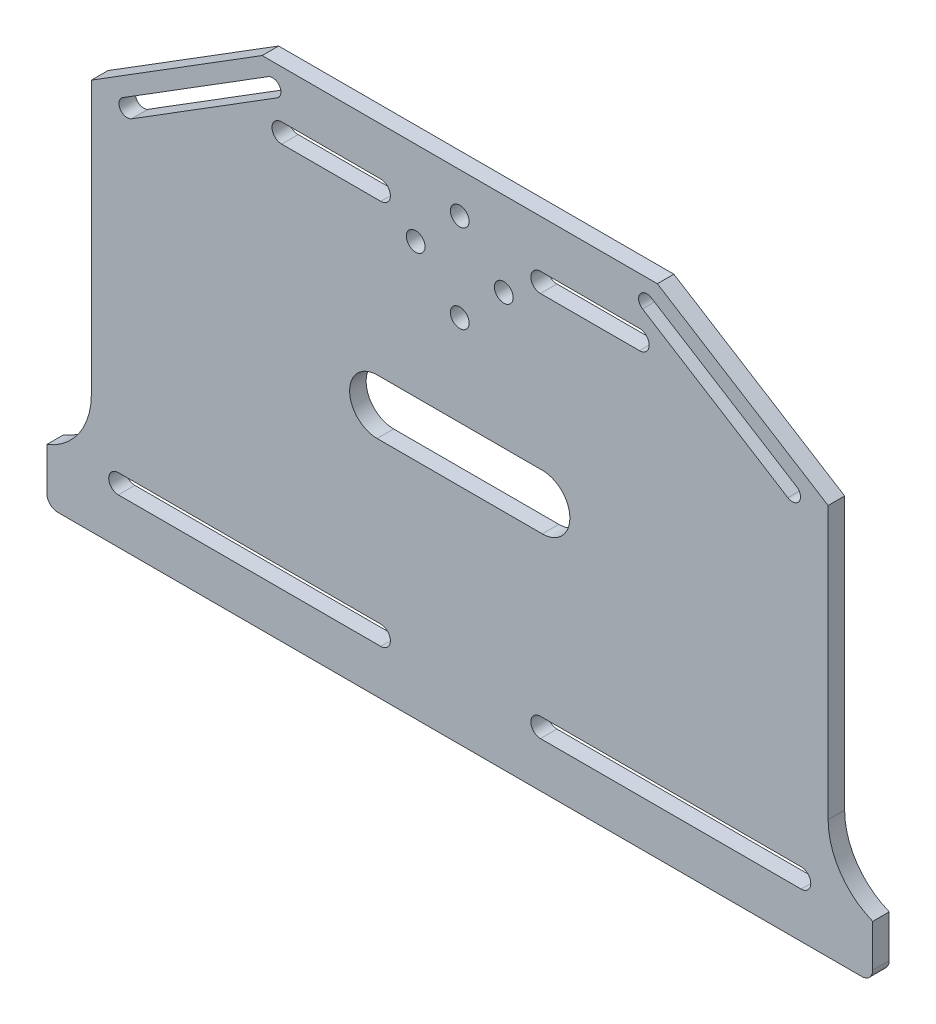
from build123d import *

# Parameters (mm, degrees)
EXTRUDE_1_DEPTH      = 3
SKETCH_7_R           = 1.75
SKETCH_7_R_2         = 2.25
CUT_EXTRUDE_2_DEPTH  = 143.955430949
CUT_EXTRUDE_4_DEPTH  = 3
CUT_EXTRUDE_5_DEPTH  = 3
CUT_EXTRUDE_8_DEPTH  = 3
SKETCH_12_R          = 1.7
CUT_EXTRUDE_9_DEPTH  = 3
SKETCH_13_R          = 1.7
CUT_EXTRUDE_11_DEPTH = 3
CUT_EXTRUDE_12_DEPTH = 143.955430949
FILLET_1_R           = 2
FILLET_2_R           = 2
CUT_EXTRUDE_13_DEPTH = 143.955430949
CUT_EXTRUDE_15_DEPTH = 143.955430949
CUT_EXTRUDE_16_DEPTH = 143.955430949
SKETCH_20_W          = 133.80338819
SKETCH_20_H          = 42.989432067
EXTRUDE_2_DEPTH      = 3
SKETCH_21_W          = 129.207272524
SKETCH_21_H          = 38.788932745
EXTRUDE_3_DEPTH      = 3
SKETCH_22_W          = 20.868569364
SKETCH_22_H          = 31.210515244
SKETCH_22_W_2        = 21.053246969
SKETCH_22_H_2        = 30.102449614
EXTRUDE_4_DEPTH      = 3
SKETCH_24_W          = 36.300662223
SKETCH_24_H          = 5.953308604
SKETCH_24_W_2        = 36.591067521
EXTRUDE_5_DEPTH      = 3
CUT_EXTRUDE_17_DEPTH = 143.955430949
CUT_EXTRUDE_19_DEPTH = 143.955430949
CUT_EXTRUDE_20_DEPTH = 143.955430949
CUT_EXTRUDE_21_DEPTH = 143.955430949
CUT_EXTRUDE_22_DEPTH = 143.955430949
CUT_EXTRUDE_23_DEPTH = 3
SKETCH_30_W          = 173.170170175
SKETCH_30_H          = 150.145671893
CUT_EXTRUDE_24_DEPTH = 10


with BuildPart() as part:
    # 草图1 → 凸台-拉伸1 (new body)
    with BuildSketch(Plane.XY):
        with BuildLine():
            Line((60, 106.603296002), (35.889163634, 121.664519159))
            Line((35.889163634, 121.664519159), (-35.889163634, 121.664519159))
            Line((-35.889163634, 121.664519159), (-60, 106.603296002))
            Line((-60, 106.603296002), (-60, 94.801892265))
            Line((-60, 94.801892265), (-45, 94.801892265))
            ThreePointArc((-45, 94.801892265), (-43.762563133, 94.289329132), (-43.25, 93.051892265))
            Line((-43.25, 93.051892265), (-37.75, 93.051892265))
            ThreePointArc((-37.75, 93.051892265), (-37.237436867, 94.289329132), (-36, 94.801892265))
            Line((-36, 94.801892265), (-21, 94.801892265))
            ThreePointArc((-21, 94.801892265), (-19.762563133, 94.289329132), (-19.25, 93.051892265))
            Line((-19.25, 93.051892265), (19.25, 93.051892265))
            ThreePointArc((19.25, 93.051892265), (19.762563133, 94.289329132), (21, 94.801892265))
            Line((21, 94.801892265), (36, 94.801892265))
            ThreePointArc((36, 94.801892265), (37.237436867, 94.289329132), (37.75, 93.051892265))
            Line((37.75, 93.051892265), (43.25, 93.051892265))
            ThreePointArc((43.25, 93.051892265), (43.762563133, 94.289329132), (45, 94.801892265))
            Line((45, 94.801892265), (60, 94.801892265))
            Line((60, 94.801892265), (60, 106.603296002))
        make_face()
        with BuildLine():
            Line((66.901694095, 102.292041372), (60, 106.603296002))
            Line((60, 106.603296002), (60, 94.801892265))
            ThreePointArc((60, 94.801892265), (61.237436867, 94.289329132), (61.75, 93.051892265))
            Line((61.75, 93.051892265), (66.901694095, 93.051892265))
            Line((66.901694095, 93.051892265), (66.901694095, 102.292041372))
        make_face()
        with BuildLine():
            Line((-60, 94.801892265), (-60, 106.603296002))
            Line((-60, 106.603296002), (-66.901694095, 102.292041372))
            Line((-66.901694095, 102.292041372), (-66.901694095, 93.051892265))
            Line((-66.901694095, 93.051892265), (-61.75, 93.051892265))
            ThreePointArc((-61.75, 93.051892265), (-61.237436867, 94.289329132), (-60, 94.801892265))
        make_face()
        with BuildLine():
            Line((66.901694095, 63.051892265), (66.901694095, 93.051892265))
            Line((66.901694095, 93.051892265), (61.75, 93.051892265))
            ThreePointArc((61.75, 93.051892265), (61.237436867, 91.814455398), (60, 91.301892265))
            Line((60, 91.301892265), (60, 64.801892265))
            ThreePointArc((60, 64.801892265), (61.237436867, 64.289329132), (61.75, 63.051892265))
            Line((61.75, 63.051892265), (66.901694095, 63.051892265))
        make_face()
        with BuildLine():
            Line((-61.75, 93.051892265), (-66.901694095, 93.051892265))
            Line((-66.901694095, 93.051892265), (-66.901694095, 63.051892265))
            Line((-66.901694095, 63.051892265), (-61.75, 63.051892265))
            ThreePointArc((-61.75, 63.051892265), (-61.237436867, 64.289329132), (-60, 64.801892265))
            Line((-60, 64.801892265), (-60, 91.301892265))
            ThreePointArc((-60, 91.301892265), (-61.237436867, 91.814455398), (-61.75, 93.051892265))
        make_face()
        with BuildLine():
            Line((66.901694095, 52.870133869), (66.901694095, 63.051892265))
            Line((66.901694095, 63.051892265), (61.75, 63.051892265))
            ThreePointArc((61.75, 63.051892265), (61.237436867, 61.814455398), (60, 61.301892265))
            Line((60, 61.301892265), (60, 31.261343001))
            Line((60, 31.261343001), (75, 31.261343001))
            Line((75, 31.261343001), (75, 40.933889795))
            ThreePointArc((75, 40.933889795), (69.117351927, 45.658052319), (66.901694095, 52.870133869))
        make_face()
        with BuildLine():
            Line((60, 64.801892265), (60, 91.301892265))
            Line((60, 91.301892265), (45, 91.301892265))
            ThreePointArc((45, 91.301892265), (43.762563133, 91.814455398), (43.25, 93.051892265))
            Line((43.25, 93.051892265), (37.75, 93.051892265))
            ThreePointArc((37.75, 93.051892265), (37.237436867, 91.814455398), (36, 91.301892265))
            Line((36, 91.301892265), (21, 91.301892265))
            ThreePointArc((21, 91.301892265), (19.762563133, 91.814455398), (19.25, 93.051892265))
            Line((19.25, 93.051892265), (-19.25, 93.051892265))
            ThreePointArc((-19.25, 93.051892265), (-19.762563133, 91.814455398), (-21, 91.301892265))
            Line((-21, 91.301892265), (-36, 91.301892265))
            ThreePointArc((-36, 91.301892265), (-37.237436867, 91.814455398), (-37.75, 93.051892265))
            Line((-37.75, 93.051892265), (-43.25, 93.051892265))
            ThreePointArc((-43.25, 93.051892265), (-43.762563133, 91.814455398), (-45, 91.301892265))
            Line((-45, 91.301892265), (-60, 91.301892265))
            Line((-60, 91.301892265), (-60, 64.801892265))
            Line((-60, 64.801892265), (-45, 64.801892265))
            ThreePointArc((-45, 64.801892265), (-43.762563133, 64.289329132), (-43.25, 63.051892265))
            Line((-43.25, 63.051892265), (-37.75, 63.051892265))
            ThreePointArc((-37.75, 63.051892265), (-37.237436867, 64.289329132), (-36, 64.801892265))
            Line((-36, 64.801892265), (-21, 64.801892265))
            ThreePointArc((-21, 64.801892265), (-19.762563133, 64.289329132), (-19.25, 63.051892265))
            Line((-19.25, 63.051892265), (19.25, 63.051892265))
            ThreePointArc((19.25, 63.051892265), (19.762563133, 64.289329132), (21, 64.801892265))
            Line((21, 64.801892265), (36, 64.801892265))
            ThreePointArc((36, 64.801892265), (37.237436867, 64.289329132), (37.75, 63.051892265))
            Line((37.75, 63.051892265), (43.25, 63.051892265))
            ThreePointArc((43.25, 63.051892265), (43.762563133, 64.289329132), (45, 64.801892265))
            Line((45, 64.801892265), (60, 64.801892265))
        make_face()
        with BuildLine():
            Line((-61.75, 63.051892265), (-66.901694095, 63.051892265))
            Line((-66.901694095, 63.051892265), (-66.901694095, 52.870133869))
            ThreePointArc((-66.901694095, 52.870133869), (-69.117351927, 45.658052319), (-75, 40.933889795))
            Line((-75, 40.933889795), (-75, 31.261343001))
            Line((-75, 31.261343001), (-60, 31.261343001))
            Line((-60, 31.261343001), (-60, 61.301892265))
            ThreePointArc((-60, 61.301892265), (-61.237436867, 61.814455398), (-61.75, 63.051892265))
        make_face()
        with BuildLine():
            Line((60, 31.261343001), (60, 61.301892265))
            Line((60, 61.301892265), (45, 61.301892265))
            ThreePointArc((45, 61.301892265), (43.762563133, 61.814455398), (43.25, 63.051892265))
            Line((43.25, 63.051892265), (37.75, 63.051892265))
            ThreePointArc((37.75, 63.051892265), (37.237436867, 61.814455398), (36, 61.301892265))
            Line((36, 61.301892265), (21, 61.301892265))
            ThreePointArc((21, 61.301892265), (19.762563133, 61.814455398), (19.25, 63.051892265))
            Line((19.25, 63.051892265), (-19.25, 63.051892265))
            ThreePointArc((-19.25, 63.051892265), (-19.762563133, 61.814455398), (-21, 61.301892265))
            Line((-21, 61.301892265), (-36, 61.301892265))
            ThreePointArc((-36, 61.301892265), (-37.237436867, 61.814455398), (-37.75, 63.051892265))
            Line((-37.75, 63.051892265), (-43.25, 63.051892265))
            ThreePointArc((-43.25, 63.051892265), (-43.762563133, 61.814455398), (-45, 61.301892265))
            Line((-45, 61.301892265), (-60, 61.301892265))
            Line((-60, 61.301892265), (-60, 31.261343001))
            Line((-60, 31.261343001), (60, 31.261343001))
        make_face()
        with BuildLine():
            Line((60, -58.312864289), (60, 23.940028391))
            Line((60, 23.940028391), (-60, 23.940028391))
            Line((-60, 23.940028391), (-60, -58.312864289))
            Line((-60, -58.312864289), (-45, -58.312864289))
            ThreePointArc((-45, -58.312864289), (-43.25, -60.062864289), (-45, -61.812864289))
            Line((-45, -61.812864289), (-60, -61.812864289))
            Line((-60, -61.812864289), (-60, -88.312864289))
            Line((-60, -88.312864289), (-45, -88.312864289))
            ThreePointArc((-45, -88.312864289), (-43.25, -90.062864289), (-45, -91.812864289))
            Line((-45, -91.812864289), (-60, -91.812864289))
            Line((-60, -91.812864289), (-60, -111.849967256))
            Line((-60, -111.849967256), (-38.845469114, -105.590576733))
            ThreePointArc((-38.845469114, -105.590576733), (-36.037784492, -104.975210108), (-33.17088573, -104.768665882))
            Line((-33.17088573, -104.768665882), (33.17088573, -104.768665882))
            ThreePointArc((33.17088573, -104.768665882), (36.037784492, -104.975210108), (38.845469114, -105.590576733))
            Line((38.845469114, -105.590576733), (60, -111.849967256))
            Line((60, -111.849967256), (60, -91.812864289))
            Line((60, -91.812864289), (45, -91.812864289))
            ThreePointArc((45, -91.812864289), (43.762563133, -91.300301156), (43.25, -90.062864289))
            ThreePointArc((43.25, -90.062864289), (43.762563133, -88.825427422), (45, -88.312864289))
            Line((45, -88.312864289), (60, -88.312864289))
            Line((60, -88.312864289), (60, -61.812864289))
            Line((60, -61.812864289), (45, -61.812864289))
            ThreePointArc((45, -61.812864289), (43.762563133, -61.300301156), (43.25, -60.062864289))
            ThreePointArc((43.25, -60.062864289), (43.762563133, -58.825427422), (45, -58.312864289))
            Line((45, -58.312864289), (60, -58.312864289))
        make_face()
        with BuildLine():
            ThreePointArc((-21, -88.312864289), (-19.762563133, -88.825427422), (-19.25, -90.062864289))
            ThreePointArc((-19.25, -90.062864289), (-19.762563133, -91.300301156), (-21, -91.812864289))
            Line((-21, -91.812864289), (-36, -91.812864289))
            ThreePointArc((-36, -91.812864289), (-37.75, -90.062864289), (-36, -88.312864289))
            Line((-36, -88.312864289), (-21, -88.312864289))
        make_face(mode=Mode.SUBTRACT)
        with BuildLine():
            ThreePointArc((-21, -58.312864289), (-19.762563133, -58.825427422), (-19.25, -60.062864289))
            ThreePointArc((-19.25, -60.062864289), (-19.762563133, -61.300301156), (-21, -61.812864289))
            Line((-21, -61.812864289), (-36, -61.812864289))
            ThreePointArc((-36, -61.812864289), (-37.75, -60.062864289), (-36, -58.312864289))
            Line((-36, -58.312864289), (-21, -58.312864289))
        make_face(mode=Mode.SUBTRACT)
        with BuildLine():
            ThreePointArc((36, -88.312864289), (37.237436867, -88.825427422), (37.75, -90.062864289))
            ThreePointArc((37.75, -90.062864289), (37.237436867, -91.300301156), (36, -91.812864289))
            Line((36, -91.812864289), (21, -91.812864289))
            ThreePointArc((21, -91.812864289), (19.762563133, -91.300301156), (19.25, -90.062864289))
            ThreePointArc((19.25, -90.062864289), (19.762563133, -88.825427422), (21, -88.312864289))
            Line((21, -88.312864289), (36, -88.312864289))
        make_face(mode=Mode.SUBTRACT)
        with BuildLine():
            ThreePointArc((36, -58.312864289), (37.237436867, -58.825427422), (37.75, -60.062864289))
            ThreePointArc((37.75, -60.062864289), (37.237436867, -61.300301156), (36, -61.812864289))
            Line((36, -61.812864289), (21, -61.812864289))
            ThreePointArc((21, -61.812864289), (19.762563133, -61.300301156), (19.25, -60.062864289))
            ThreePointArc((19.25, -60.062864289), (19.762563133, -58.825427422), (21, -58.312864289))
            Line((21, -58.312864289), (36, -58.312864289))
        make_face(mode=Mode.SUBTRACT)
        with BuildLine():
            Line((75, 23.940028391), (60, 23.940028391))
            Line((60, 23.940028391), (60, -58.312864289))
            ThreePointArc((60, -58.312864289), (61.237436867, -58.825427422), (61.75, -60.062864289))
            Line((61.75, -60.062864289), (67.402721334, -60.062864289))
            add(Edge.make_bspline(
                [(75, 10.562559835), (72.695878257, 1.907314233), (70.339582535, -13.372796253), (67.818206704, -36.939032951), (67.208860388, -51.77269444), (67.402721334, -60.062864289)],
                knots=[0, 0, 0, 0, 0.235246678, 0.40629419, 0.624108181, 0.624108181, 0.624108181, 0.624108181], degree=3))
            Line((75, 10.562559835), (75, 23.940028391))
        make_face()
        with BuildLine():
            Line((-60, -58.312864289), (-60, 23.940028391))
            Line((-60, 23.940028391), (-75, 23.940028391))
            Line((-75, 23.940028391), (-75, 10.562559835))
            add(Edge.make_bspline(
                [(-75, 10.562559835), (-72.695878257, 1.907314233), (-70.339582535, -13.372796253), (-67.818206704, -36.939032951), (-67.208860388, -51.77269444), (-67.402721334, -60.062864289)],
                knots=[0, 0, 0, 0, 0.235246678, 0.40629419, 0.624108181, 0.624108181, 0.624108181, 0.624108181], degree=3))
            add(Edge.make_bspline(
                [(-67.402721334, -60.062864289), (-67.560325872, -66.802583754), (-68.323504015, -76.843670093), (-70.154131955, -86.778530076), (-70.533712858, -90.062864289)],
                knots=[0.624108181, 0.624108181, 0.624108181, 0.624108181, 0.801186001, 0.888408652, 0.888408652, 0.888408652, 0.888408652], degree=3))
            add(Edge.make_bspline(
                [(-70.533712858, -90.062864289), (-71.019342956, -94.264792095), (-71.137422935, -98.476048206), (-70.1742624, -102.732794059)],
                knots=[0.888408652, 0.888408652, 0.888408652, 0.888408652, 1, 1, 1, 1], degree=3))
            Line((-70.1742624, -102.732794059), (-66.460817635, -113.761651372))
            Line((-66.460817635, -113.761651372), (-60, -111.849967256))
            Line((-60, -111.849967256), (-60, -91.812864289))
            ThreePointArc((-60, -91.812864289), (-61.75, -90.062864289), (-60, -88.312864289))
            Line((-60, -88.312864289), (-60, -61.812864289))
            ThreePointArc((-60, -61.812864289), (-61.75, -60.062864289), (-60, -58.312864289))
        make_face()
        with BuildLine():
            Line((67.402721334, -60.062864289), (61.75, -60.062864289))
            ThreePointArc((61.75, -60.062864289), (61.237436867, -61.300301156), (60, -61.812864289))
            Line((60, -61.812864289), (60, -88.312864289))
            ThreePointArc((60, -88.312864289), (61.237436867, -88.825427422), (61.75, -90.062864289))
            Line((61.75, -90.062864289), (70.533712858, -90.062864289))
            add(Edge.make_bspline(
                [(67.402721334, -60.062864289), (67.560325872, -66.802583754), (68.323504015, -76.843670093), (70.154131955, -86.778530076), (70.533712858, -90.062864289)],
                knots=[0.624108181, 0.624108181, 0.624108181, 0.624108181, 0.801186001, 0.888408652, 0.888408652, 0.888408652, 0.888408652], degree=3))
        make_face()
        with BuildLine():
            add(Edge.make_bspline(
                [(70.533712858, -90.062864289), (71.019342956, -94.264792095), (71.137422935, -98.476048206), (70.1742624, -102.732794059)],
                knots=[0.888408652, 0.888408652, 0.888408652, 0.888408652, 1, 1, 1, 1], degree=3))
            Line((70.533712858, -90.062864289), (61.75, -90.062864289))
            ThreePointArc((61.75, -90.062864289), (61.237436867, -91.300301156), (60, -91.812864289))
            Line((60, -91.812864289), (60, -111.849967256))
            Line((60, -111.849967256), (66.460817635, -113.761651372))
            Line((66.460817635, -113.761651372), (70.1742624, -102.732794059))
        make_face()
    extrude(amount=EXTRUDE_1_DEPTH)

    # 草图7 → 切除-拉伸2 (cut, through all)
    with BuildSketch(Plane(origin=(0, 0, 0), x_dir=(-1, 0, 0), z_dir=(0, 0, -1))):
        with Locations((-21, 41.261343001)):
            Circle(SKETCH_7_R)
        with Locations((21, 41.261343001)):
            Circle(SKETCH_7_R)
        with Locations((-21, 13.940028391)):
            Circle(SKETCH_7_R_2)
        with Locations((21, 13.940028391)):
            Circle(SKETCH_7_R_2)
    extrude(amount=-CUT_EXTRUDE_2_DEPTH, mode=Mode.SUBTRACT)

    # 草图9 → 切除-拉伸4 (cut)
    with BuildSketch(Plane.XY.offset(3)):
        with BuildLine():
            Line((55, -100.49704609), (20, -100.49704609))
            ThreePointArc((20, -100.49704609), (18.25, -98.74704609), (20, -96.99704609))
            Line((20, -96.99704609), (55, -96.99704609))
            ThreePointArc((55, -96.99704609), (56.75, -98.74704609), (55, -100.49704609))
        make_face()
        with BuildLine():
            Line((-55, -96.99704609), (-20, -96.99704609))
            ThreePointArc((-20, -96.99704609), (-18.25, -98.74704609), (-20, -100.49704609))
            Line((-20, -100.49704609), (-55, -100.49704609))
            ThreePointArc((-55, -100.49704609), (-56.75, -98.74704609), (-55, -96.99704609))
        make_face()
    extrude(amount=-CUT_EXTRUDE_4_DEPTH, mode=Mode.SUBTRACT)

    # 草图10 → 切除-拉伸5 (cut)
    with BuildSketch(Plane.XY.offset(3)):
        with BuildLine():
            Line((12.5, -80.062864289), (-12.5, -80.062864289))
            ThreePointArc((-12.5, -80.062864289), (-17.5, -75.062864289), (-12.5, -70.062864289))
            Line((-12.5, -70.062864289), (12.5, -70.062864289))
            ThreePointArc((12.5, -70.062864289), (17.5, -75.062864289), (12.5, -80.062864289))
        make_face()
    extrude(amount=-CUT_EXTRUDE_5_DEPTH, mode=Mode.SUBTRACT)

    # 草图11 → 切除-拉伸8 (cut)
    with BuildSketch(Plane.XY.offset(3)):
        with BuildLine():
            Line((15, 73.051892265), (-15, 73.051892265))
            ThreePointArc((-15, 73.051892265), (-20, 78.051892265), (-15, 83.051892265))
            Line((-15, 83.051892265), (15, 83.051892265))
            ThreePointArc((15, 83.051892265), (20, 78.051892265), (15, 73.051892265))
        make_face()
    extrude(amount=-CUT_EXTRUDE_8_DEPTH, mode=Mode.SUBTRACT)

    # 草图12 → 切除-拉伸9 (cut)
    with BuildSketch(Plane.XY.offset(3)):
        with Locations((0, 114.371786435)):
            Circle(SKETCH_12_R)
        with Locations((0, 98.371786435)):
            Circle(SKETCH_12_R)
        with Locations((8, 106.371786435)):
            Circle(SKETCH_12_R)
        with Locations((-8, 106.371786435)):
            Circle(SKETCH_12_R)
    extrude(amount=-CUT_EXTRUDE_9_DEPTH, mode=Mode.SUBTRACT)

    # 草图13 → 切除-拉伸11 (cut)
    with BuildSketch(Plane.XY.offset(3)):
        with Locations((0, -84.415765086)):
            Circle(SKETCH_13_R)
        with Locations((8, -92.415765086)):
            Circle(SKETCH_13_R)
        with Locations((0, -100.415765086)):
            Circle(SKETCH_13_R)
        with Locations((-8, -92.415765086)):
            Circle(SKETCH_13_R)
    extrude(amount=-CUT_EXTRUDE_11_DEPTH, mode=Mode.SUBTRACT)

    # 草图14 → 切除-拉伸12 (cut, through all)
    with BuildSketch(Plane.XY.offset(3)):
        with BuildLine():
            Line((-55.475501567, 8.919687236), (-55.475501567, -46.080312764))
            ThreePointArc((-55.475501567, -46.080312764), (-57.225501567, -47.830312764), (-58.975501567, -46.080312764))
            Line((-58.975501567, -46.080312764), (-58.975501567, 8.919687236))
            ThreePointArc((-58.975501567, 8.919687236), (-57.225501567, 10.669687236), (-55.475501567, 8.919687236))
        make_face()
        with BuildLine():
            Line((58.975501567, 8.919687236), (58.975501567, -46.080312764))
            ThreePointArc((58.975501567, -46.080312764), (57.225501567, -47.830312764), (55.475501567, -46.080312764))
            Line((55.475501567, -46.080312764), (55.475501567, 8.919687236))
            ThreePointArc((55.475501567, 8.919687236), (57.225501567, 10.669687236), (58.975501567, 8.919687236))
        make_face()
    extrude(amount=-CUT_EXTRUDE_12_DEPTH, mode=Mode.SUBTRACT)

    # 圆角1
    fillet_1_edges = [part.edges().sort_by_distance(p)[0] for p in [
        (75, 31.261343001, 1.5),
        (-75, 31.261343001, 1.5),
    ]]
    fillet(fillet_1_edges, radius=FILLET_1_R)

    # 圆角2
    fillet_2_edges = [part.edges().sort_by_distance(p)[0] for p in [
        (-75, 23.940028391, 1.5),
        (75, 23.940028391, 1.5),
    ]]
    fillet(fillet_2_edges, radius=FILLET_2_R)

    # 草图15 → 切除-拉伸13 (cut, through all)
    with BuildSketch(Plane(origin=(0, 0, 0), x_dir=(-1, 0, 0), z_dir=(0, 0, -1))):
        with BuildLine():
            Line((-61.184216401, 102.403501276), (-34.774762862, 118.900592756))
            ThreePointArc((-34.774762862, 118.900592756), (-32.70788159, 118.423097411), (-33.185376934, 116.356216138))
            Line((-33.185376934, 116.356216138), (-59.594830473, 99.859124658))
            ThreePointArc((-59.594830473, 99.859124658), (-61.661711746, 100.336620003), (-61.184216401, 102.403501276))
        make_face()
        with BuildLine():
            Line((59.594830473, 99.859124658), (33.185376934, 116.356216138))
            ThreePointArc((33.185376934, 116.356216138), (32.70788159, 118.423097411), (34.774762862, 118.900592756))
            Line((34.774762862, 118.900592756), (61.184216401, 102.403501276))
            ThreePointArc((61.184216401, 102.403501276), (61.661711746, 100.336620003), (59.594830473, 99.859124658))
        make_face()
    extrude(amount=-CUT_EXTRUDE_13_DEPTH, mode=Mode.SUBTRACT)

    # 草图17 → 切除-拉伸15 (cut, through all)
    with BuildSketch(Plane(origin=(0, 0, 0), x_dir=(-1, 0, 0), z_dir=(0, 0, -1))):
        Polygon((-28.645414283, -8.118433382), (-34.644957411, -20.11751964), (-34.644957411, -29.946558382), (-37.580904049, -29.946558382), (-37.580904049, -20.11751964), (-43.580447177, -8.118433382), (-40.64450054, -8.118433382), (-36.176755657, -17.43687271), (-36.049105803, -17.43687271), (-31.58136092, -8.118433382), align=None)
    extrude(amount=-CUT_EXTRUDE_15_DEPTH, mode=Mode.SUBTRACT)

    # 草图18 → 切除-拉伸16 (cut, through all)
    with BuildSketch(Plane(origin=(0, 0, 0), x_dir=(-1, 0, 0), z_dir=(0, 0, -1))):
        Polygon((46.06697123, -29.087529791), (43.131024593, -29.087529791), (43.131024593, -18.875541487), (35.854982926, -18.875541487), (35.854982926, -29.087529791), (32.919036289, -29.087529791), (32.919036289, -7.259404791), (35.854982926, -7.259404791), (35.854982926, -16.450194265), (43.131024593, -16.450194265), (43.131024593, -7.259404791), (46.06697123, -7.259404791), align=None)
    extrude(amount=-CUT_EXTRUDE_16_DEPTH, mode=Mode.SUBTRACT)

    # 草图20 → 凸台-拉伸2 (add)
    with BuildSketch(Plane(origin=(0, 0, 0), x_dir=(-1, 0, 0), z_dir=(0, 0, -1))):
        with Locations((0, 74.364849902)):
            Rectangle(SKETCH_20_W, SKETCH_20_H)
    extrude(amount=-EXTRUDE_2_DEPTH)

    # 草图21 → 凸台-拉伸3 (add)
    with BuildSketch(Plane(origin=(0, 0, 0), x_dir=(-1, 0, 0), z_dir=(0, 0, -1))):
        with Locations((-0.162688936, -75.817262983)):
            Rectangle(SKETCH_21_W, SKETCH_21_H)
    extrude(amount=-EXTRUDE_3_DEPTH)

    # 草图22 → 凸台-拉伸4 (add)
    with BuildSketch(Plane(origin=(0, 0, 0), x_dir=(-1, 0, 0), z_dir=(0, 0, -1))):
        with Locations((-36.28455521, -18.718035035)):
            Rectangle(SKETCH_22_W, SKETCH_22_H)
        with Locations((39.340924035, -18.16400222)):
            Rectangle(SKETCH_22_W_2, SKETCH_22_H_2)
    extrude(amount=-EXTRUDE_4_DEPTH)

    # 草图24 → 凸台-拉伸5 (add)
    with BuildSketch(Plane(origin=(0, 0, 0), x_dir=(-1, 0, 0), z_dir=(0, 0, -1))):
        with Locations((-46.84572901, 41.350914957)):
            Rectangle(SKETCH_24_W, SKETCH_24_H)
        with Locations((47.53599277, 41.350914957)):
            Rectangle(SKETCH_24_W_2, SKETCH_24_H)
    extrude(amount=-EXTRUDE_5_DEPTH)

    # 草图25 → 切除-拉伸17 (cut, through all)
    with BuildSketch(Plane(origin=(0, 0, 0), x_dir=(-1, 0, 0), z_dir=(0, 0, -1))):
        with BuildLine():
            Line((-14.658238954, 113.011343001), (-32.658238954, 113.011343001))
            ThreePointArc((-32.658238954, 113.011343001), (-34.408238954, 111.261343001), (-32.658238954, 109.511343001))
            Line((-32.658238954, 109.511343001), (-14.658238954, 109.511343001))
            ThreePointArc((-14.658238954, 109.511343001), (-12.908238954, 111.261343001), (-14.658238954, 113.011343001))
        make_face()
        with BuildLine():
            Line((-20.999999982, 43.011343001), (-32.658238954, 43.011343001))
            ThreePointArc((-32.658238954, 43.011343001), (-34.408238954, 41.261343001), (-32.658238954, 39.511343001))
            Line((-32.658238954, 39.511343001), (-21, 39.511343001))
            ThreePointArc((-21, 39.511343001), (-22.75, 41.26134301), (-20.999999982, 43.011343001))
        make_face()
        with BuildLine():
            ThreePointArc((14.341761046, 113.011343001), (12.591761046, 111.261343001), (14.341761046, 109.511343001))
            Line((14.341761046, 109.511343001), (32.341761046, 109.511343001))
            ThreePointArc((32.341761046, 109.511343001), (34.091761046, 111.261343001), (32.341761046, 113.011343001))
            Line((32.341761046, 113.011343001), (14.341761046, 113.011343001))
        make_face()
        with BuildLine():
            Line((-14.658238954, 43.011343001), (-20.999999982, 43.011343001))
            ThreePointArc((-20.999999982, 43.011343001), (-19.25, 41.261342991), (-21, 39.511343001))
            Line((-21, 39.511343001), (-14.658238954, 39.511343001))
            ThreePointArc((-14.658238954, 39.511343001), (-12.908238954, 41.261343001), (-14.658238954, 43.011343001))
        make_face()
        with BuildLine():
            ThreePointArc((32.341761046, 39.511343001), (34.091761046, 41.261343001), (32.341761046, 43.011343001))
            Line((32.341761046, 43.011343001), (21, 43.011343001))
            ThreePointArc((21, 43.011343001), (22.75, 41.261343001), (21, 39.511343001))
            Line((21, 39.511343001), (32.341761046, 39.511343001))
        make_face()
        with BuildLine():
            ThreePointArc((14.341761046, 43.011343001), (12.591761046, 41.261343001), (14.341761046, 39.511343001))
            Line((14.341761046, 39.511343001), (21, 39.511343001))
            ThreePointArc((21, 39.511343001), (19.25, 41.261343001), (21, 43.011343001))
            Line((21, 43.011343001), (14.341761046, 43.011343001))
        make_face()
    extrude(amount=-CUT_EXTRUDE_17_DEPTH, mode=Mode.SUBTRACT)

    # 草图16 → 切除-拉伸19 (cut, through all)
    with BuildSketch(Plane(origin=(0, 0, 0), x_dir=(-1, 0, 0), z_dir=(0, 0, -1))):
        with BuildLine():
            Line((-62, 43.011343001), (-32, 43.011343001))
            ThreePointArc((-32, 43.011343001), (-30.25, 41.261343001), (-32, 39.511343001))
            Line((-32, 39.511343001), (-62, 39.511343001))
            ThreePointArc((-62, 39.511343001), (-63.75, 41.261343001), (-62, 43.011343001))
        make_face()
        with BuildLine():
            Line((62, 39.511343001), (32, 39.511343001))
            ThreePointArc((32, 39.511343001), (30.25, 41.261343001), (32, 43.011343001))
            Line((32, 43.011343001), (62, 43.011343001))
            ThreePointArc((62, 43.011343001), (63.75, 41.261343001), (62, 39.511343001))
        make_face()
    extrude(amount=-CUT_EXTRUDE_19_DEPTH, mode=Mode.SUBTRACT)

    # 草图26 → 切除-拉伸20 (cut, through all)
    with BuildSketch(Plane(origin=(0, 0, 0), x_dir=(-1, 0, 0), z_dir=(0, 0, -1))):
        with BuildLine():
            Line((15, 71.876956146), (-15, 71.876956146))
            ThreePointArc((-15, 71.876956146), (-20, 76.876956146), (-15, 81.876956146))
            Line((-15, 81.876956146), (15, 81.876956146))
            ThreePointArc((15, 81.876956146), (20, 76.876956146), (15, 71.876956146))
        make_face()
    extrude(amount=-CUT_EXTRUDE_20_DEPTH, mode=Mode.SUBTRACT)

    # 草图27 → 切除-拉伸21 (cut, through all)
    with BuildSketch(Plane(origin=(0, 0, 0), x_dir=(-1, 0, 0), z_dir=(0, 0, -1))):
        with BuildLine():
            Line((-10, -15.809971609), (-42.5, -15.809971609))
            ThreePointArc((-42.5, -15.809971609), (-44.25, -17.559971609), (-42.5, -19.309971609))
            Line((-42.5, -19.309971609), (-10, -19.309971609))
            ThreePointArc((-10, -19.309971609), (-8.25, -17.559971609), (-10, -15.809971609))
        make_face()
        with BuildLine():
            ThreePointArc((-42.5, 7.190028391), (-44.25, 5.440028391), (-42.5, 3.690028391))
            Line((-42.5, 3.690028391), (-10, 3.690028391))
            ThreePointArc((-10, 3.690028391), (-8.25, 5.440028391), (-10, 7.190028391))
            Line((-10, 7.190028391), (-42.5, 7.190028391))
        make_face()
        with BuildLine():
            Line((42.5, -15.809971609), (10, -15.809971609))
            ThreePointArc((10, -15.809971609), (8.25, -17.559971609), (10, -19.309971609))
            Line((10, -19.309971609), (42.5, -19.309971609))
            ThreePointArc((42.5, -19.309971609), (44.25, -17.559971609), (42.5, -15.809971609))
        make_face()
        with BuildLine():
            Line((42.5, 7.190028391), (10, 7.190028391))
            ThreePointArc((10, 7.190028391), (8.25, 5.440028391), (10, 3.690028391))
            Line((10, 3.690028391), (42.5, 3.690028391))
            ThreePointArc((42.5, 3.690028391), (44.25, 5.440028391), (42.5, 7.190028391))
        make_face()
    extrude(amount=-CUT_EXTRUDE_21_DEPTH, mode=Mode.SUBTRACT)

    # 草图28 → 切除-拉伸22 (cut, through all)
    with BuildSketch(Plane(origin=(0, 0, 0), x_dir=(-1, 0, 0), z_dir=(0, 0, -1))):
        with BuildLine():
            ThreePointArc((0, -48.812330529), (-7.86916468, -46.39674179), (-10.284753419, -54.26590647))
            ThreePointArc((-10.284753419, -54.26590647), (-5.977554294, -59.915955393), (0, -63.755729058))
            ThreePointArc((0, -63.755729058), (5.977554294, -59.915955393), (10.284753419, -54.26590647))
            ThreePointArc((10.284753419, -54.26590647), (7.86916468, -46.39674179), (0, -48.812330529))
        make_face()
    extrude(amount=-CUT_EXTRUDE_22_DEPTH, mode=Mode.SUBTRACT)

    # 草图29 → 切除-拉伸23 (cut)
    with BuildSketch(Plane(origin=(0, 0, 0), x_dir=(-1, 0, 0), z_dir=(0, 0, -1))):
        with BuildLine():
            ThreePointArc((-21.368709037, -73.490793052), (0, -84.713248851), (21.368709037, -73.490793052))
            ThreePointArc((21.368709037, -73.490793052), (23.760053677, -73.051240341), (24.199606389, -75.442584981))
            ThreePointArc((24.199606389, -75.442584981), (0, -88.151776376), (-24.199606389, -75.442584981))
            ThreePointArc((-24.199606389, -75.442584981), (-23.760053677, -73.051240341), (-21.368709037, -73.490793052))
        make_face()
    extrude(amount=-CUT_EXTRUDE_23_DEPTH, mode=Mode.SUBTRACT)

    # 草图30 → 切除-拉伸24 (cut)
    with BuildSketch(Plane.XY.offset(3)):
        with Locations((4.215753206, -48.583336833)):
            Rectangle(SKETCH_30_W, SKETCH_30_H)
    extrude(amount=-CUT_EXTRUDE_24_DEPTH, mode=Mode.SUBTRACT)


solid = part.part
